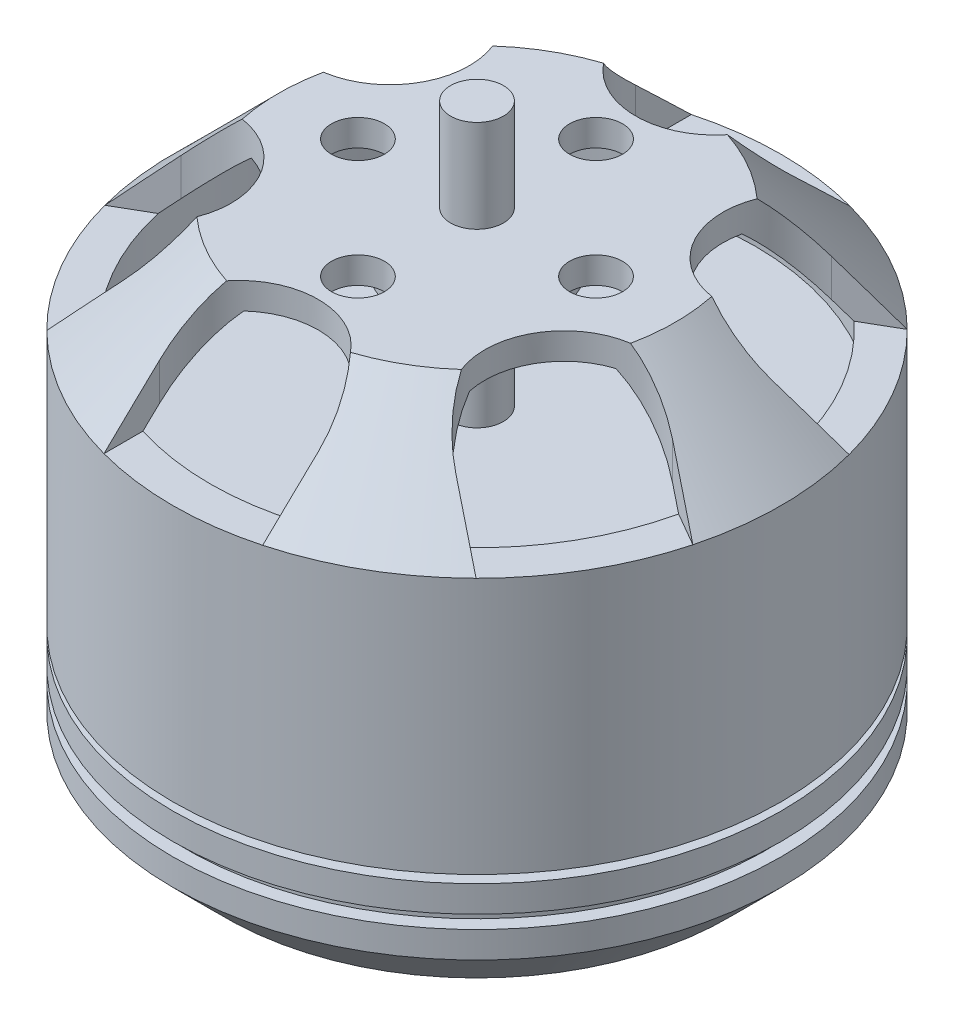
from build123d import *

# Parameters (mm, degrees)
SKETCH2_R          = 1
CUT_EXTRUDE1_DEPTH = 4
SKETCH3_R          = 1
CUT_EXTRUDE2_DEPTH = 3


with BuildPart() as part:
    # Sketch1 → Revolve1 (revolve)
    with BuildSketch(Plane.XY):
        Polygon((0, 0), (0, 21.281896562), (1, 21.281896562), (1, 17.781896562), (7.5, 17.781896562), (11.5, 13.781896562), (11.5, 4.081896562), (9.5, 4.081896562), (9.5, 3.781896562), (11.5, 3.781896562), (11.5, 2.781896562), (11, 2.781896562), (11, 2.281896562), (11.5, 2.281896562), (11.5, 1.281896562), (9.5, -0.718103438), (1, -0.718103438), (1, -2.518103438), (0, -2.518103438), align=None)
        Polygon((2.900417255, 16.781896562), (7.085786438, 16.781896562), (10.5, 13.367683), (10.5, 11.281274074), (1, 11.281274074), (1, 15.781896562), (2.900417255, 15.781896562), align=None, mode=Mode.SUBTRACT)
    revolve(axis=Axis((0, 0, 0), (0, 1, 0)))

    # Sketch2 → Cut-Extrude1 (cut)
    with BuildSketch(Plane(origin=(0, 17.781896562, 0), x_dir=(1, 0, 0), z_dir=(0, 1, 0))):
        with Locations((0, -4.5)):
            Circle(SKETCH2_R)
        with Locations((-4.5, 0)):
            Circle(SKETCH2_R)
        with Locations((0, 4.5)):
            Circle(SKETCH2_R)
        with Locations((4.5, 0)):
            Circle(SKETCH2_R)
        with BuildLine():
            Line((9.294228634, 1.901923789), (15.702595712, 5.601796246))
            Line((15.702595712, 5.601796246), (12.702595712, 10.797948669))
            Line((12.702595712, 10.797948669), (6.294228634, 7.098076211))
            ThreePointArc((6.294228634, 7.098076211), (5.196152423, 3), (9.294228634, 1.901923789))
        make_face()
        with BuildLine():
            Line((-3, 9), (-3, 16.399744914))
            Line((-3, 16.399744914), (3, 16.399744914))
            Line((3, 16.399744914), (3, 9))
            ThreePointArc((3, 9), (0, 6), (-3, 9))
        make_face()
        with BuildLine():
            Line((6.294228634, -7.098076211), (12.702595712, -10.797948669))
            Line((12.702595712, -10.797948669), (15.702595712, -5.601796246))
            Line((15.702595712, -5.601796246), (9.294228634, -1.901923789))
            ThreePointArc((9.294228634, -1.901923789), (5.196152423, -3), (6.294228634, -7.098076211))
        make_face()
        with BuildLine():
            Line((-3, -9), (-3, -16.399744914))
            Line((-3, -16.399744914), (3, -16.399744914))
            Line((3, -16.399744914), (3, -9))
            ThreePointArc((3, -9), (0, -6), (-3, -9))
        make_face()
        with BuildLine():
            Line((-9.294228634, -1.901923789), (-15.702595711, -5.601796246))
            Line((-15.702595711, -5.601796246), (-12.702595711, -10.797948669))
            Line((-12.702595711, -10.797948669), (-6.294228634, -7.098076211))
            ThreePointArc((-6.294228634, -7.098076211), (-5.196152423, -3), (-9.294228634, -1.901923789))
        make_face()
        with BuildLine():
            Line((-6.294228634, 7.098076211), (-12.702595712, 10.797948669))
            Line((-12.702595712, 10.797948669), (-15.702595712, 5.601796246))
            Line((-15.702595712, 5.601796246), (-9.294228634, 1.901923789))
            ThreePointArc((-9.294228634, 1.901923789), (-5.196152423, 3), (-6.294228634, 7.098076211))
        make_face()
    extrude(amount=-CUT_EXTRUDE1_DEPTH, mode=Mode.SUBTRACT)

    # Sketch3 → Cut-Extrude2 (cut)
    with BuildSketch(Plane.XZ.offset(0.718103438)):
        with Locations((8, 0)):
            Circle(SKETCH3_R)
        with Locations((-8, 0)):
            Circle(SKETCH3_R)
        with Locations((0, 6)):
            Circle(SKETCH3_R)
        with Locations((0, -6)):
            Circle(SKETCH3_R)
    extrude(amount=-CUT_EXTRUDE2_DEPTH, mode=Mode.SUBTRACT)


solid = part.part
